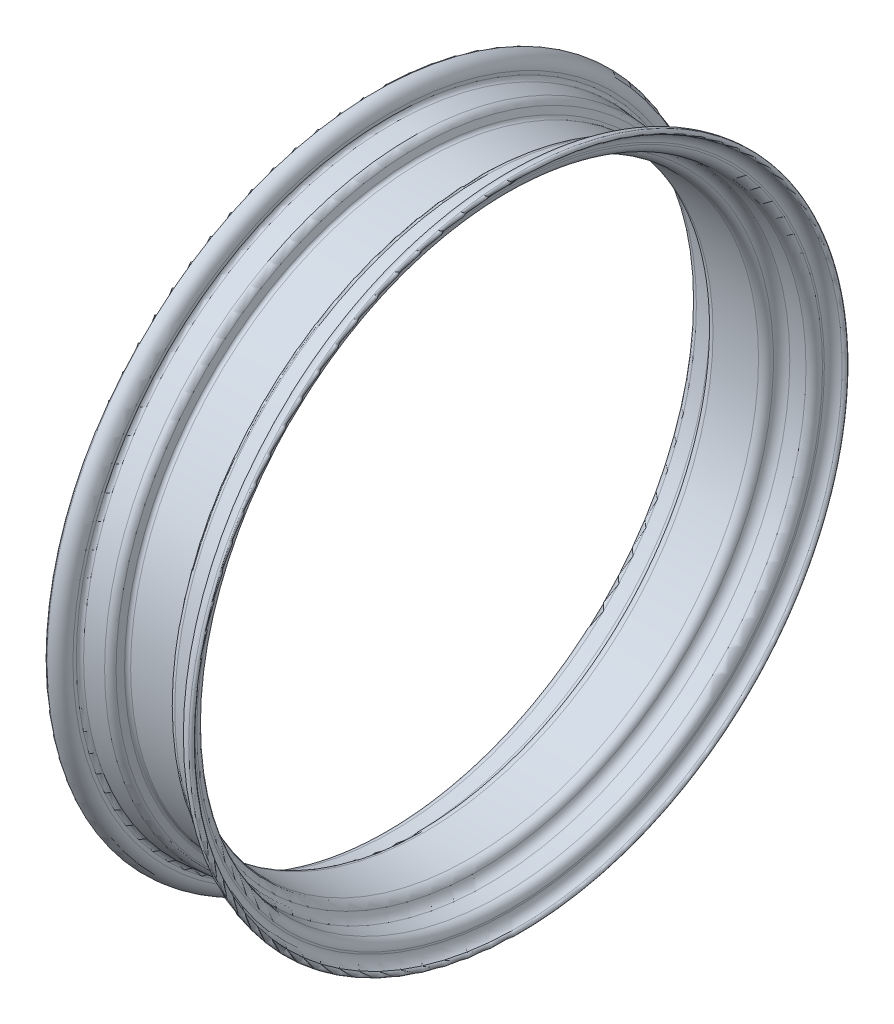
from build123d import *


with BuildPart() as part:
    # rimProfile → Revolve1 (revolve)
    with BuildSketch(Plane.XY):
        with BuildLine():
            Line((-35.717889357, 202.9), (-23.028466345, 201.78981934))
            ThreePointArc((-23.028466345, 201.78981934), (-20.420437913, 200.775612551), (-18.765781955, 198.518946566))
            Line((-18.765781955, 198.518946566), (-17.279262882, 194.434768981))
            ThreePointArc((-17.279262882, 194.434768981), (-16.363972421, 193.241939229), (-14.93003133, 192.78981934))
            Line((-14.93003133, 192.78981934), (14.93003133, 192.78981934))
            ThreePointArc((14.93003133, 192.78981934), (16.363972421, 193.241939229), (17.279262882, 194.434768981))
            Line((17.279262882, 194.434768981), (18.765781955, 198.518946566))
            ThreePointArc((18.765781955, 198.518946566), (20.420437913, 200.775612551), (23.028466345, 201.78981934))
            Line((23.028466345, 201.78981934), (35.717889357, 202.9))
            ThreePointArc((35.717889357, 202.9), (37.343193342, 203.701511226), (38, 205.390486745))
            Line((38, 205.390486745), (38, 207.588294139))
            ThreePointArc((38, 207.588294139), (40.48959236, 213.598701779), (46.5, 216.088294139))
            ThreePointArc((46.5, 216.088294139), (48.0875, 214.500794139), (46.5, 212.913294139))
            ThreePointArc((46.5, 212.913294139), (42.678458664, 210.734032569), (41.166477478, 206.602777061))
            Line((41.166477478, 206.602777061), (41.166477478, 205.408377222))
            ThreePointArc((41.166477478, 205.408377222), (39.672448789, 201.566488821), (35.975393113, 199.743302725))
            Line((35.975393113, 199.743302725), (26.19357204, 198.887504272))
            ThreePointArc((26.19357204, 198.887504272), (22.524512068, 197.342748576), (20.444244964, 193.948524068))
            ThreePointArc((20.444244964, 193.948524068), (18.4367231, 190.827898472), (14.93003133, 189.61481934))
            Line((14.93003133, 189.61481934), (-14.93003133, 189.61481934))
            ThreePointArc((-14.93003133, 189.61481934), (-18.4367231, 190.827898472), (-20.444244964, 193.948524068))
            ThreePointArc((-20.444244964, 193.948524068), (-22.524512068, 197.342748576), (-26.19357204, 198.887504272))
            Line((-26.19357204, 198.887504272), (-35.975393113, 199.743302725))
            ThreePointArc((-35.975393113, 199.743302725), (-39.672448789, 201.566488821), (-41.166477478, 205.408377222))
            Line((-41.166477478, 205.408377222), (-41.166477478, 206.602777061))
            ThreePointArc((-41.166477478, 206.602777061), (-42.678458664, 210.734032569), (-46.5, 212.913294139))
            ThreePointArc((-46.5, 212.913294139), (-48.0875, 214.500794139), (-46.5, 216.088294139))
            ThreePointArc((-46.5, 216.088294139), (-40.48959236, 213.598701779), (-38, 207.588294139))
            Line((-38, 207.588294139), (-38, 205.390486745))
            ThreePointArc((-38, 205.390486745), (-37.343193342, 203.701511226), (-35.717889357, 202.9))
        make_face()
    revolve(axis=Axis((-85.509169994, 0, 0), (1, 0, 0)))


solid = part.part
